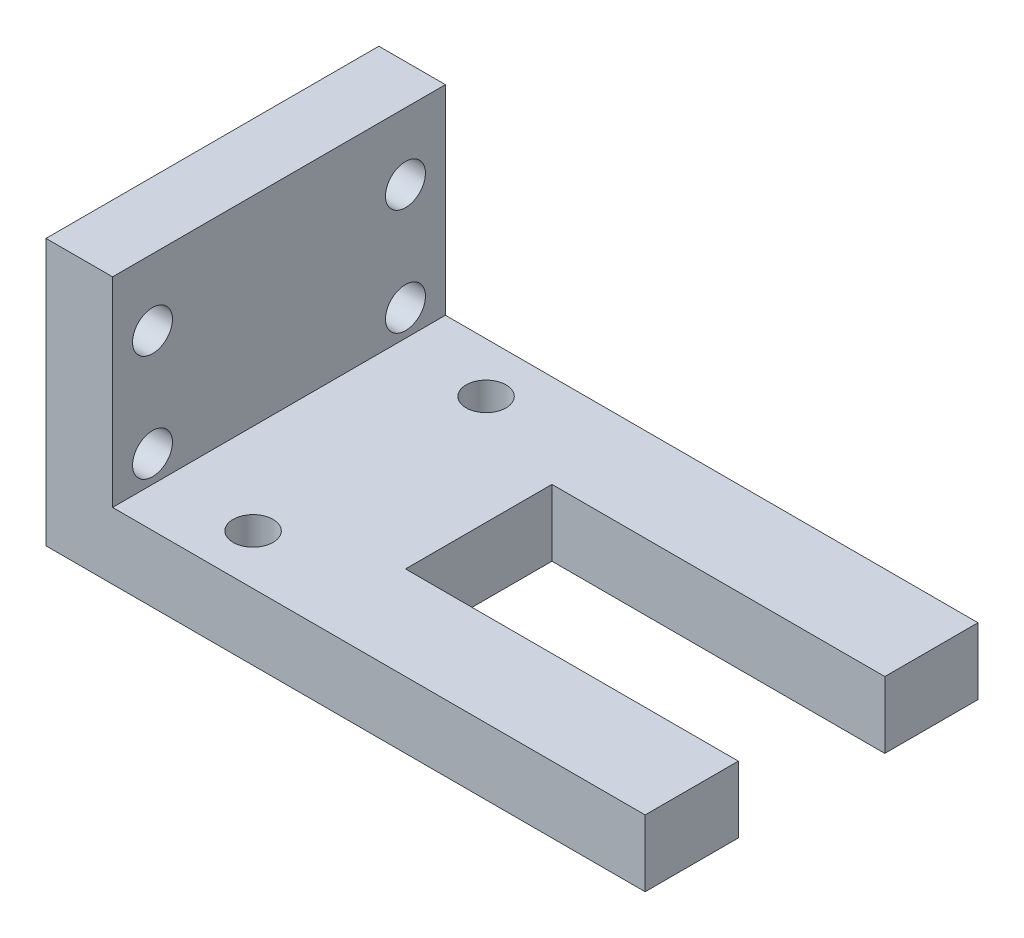
from build123d import *

# Parameters (mm, degrees)
BOSS_EXTRUDE1_DEPTH = 25
SKETCH2_R           = 1.5
CUT_EXTRUDE1_DEPTH  = 26
SKETCH3_R           = 1.5
SKETCH3_W           = 25
SKETCH3_H           = 9
CUT_EXTRUDE2_DEPTH  = 10
SKETCH5_W           = 25
SKETCH5_H           = 1
CUT_EXTRUDE3_DEPTH  = 50


with BuildPart() as part:
    # Sketch1 → Boss-Extrude1 (new body)
    with BuildSketch(Plane.XY):
        Polygon((0, 27.931034483), (0, 12.931034483), (40, 12.931034483), (40, 7.931034483), (-5, 7.931034483), (-5, 27.931034483), align=None)
    extrude(amount=-BOSS_EXTRUDE1_DEPTH)

    # Sketch2 → Cut-Extrude1 (cut)
    with BuildSketch(Plane.ZY.offset(5)):
        with Locations((-22, 22.931034483)):
            Circle(SKETCH2_R)
        with Locations((-3, 22.931034483)):
            Circle(SKETCH2_R)
        with Locations((-3, 14.931034483)):
            Circle(SKETCH2_R)
        with Locations((-22, 14.931034483)):
            Circle(SKETCH2_R)
    extrude(amount=-CUT_EXTRUDE1_DEPTH, mode=Mode.SUBTRACT)

    # Sketch3 → Cut-Extrude2 (cut)
    with BuildSketch(Plane.XZ.offset(-7.931034483)):
        with Locations((6.802030066, -3.75)):
            Circle(SKETCH3_R)
        with Locations((6.802030066, -21.25)):
            Circle(SKETCH3_R)
        with Locations((27.5, -12.5)):
            Rectangle(SKETCH3_W, SKETCH3_H)
    extrude(amount=-CUT_EXTRUDE2_DEPTH, mode=Mode.SUBTRACT)

    # Sketch5 → Cut-Extrude3 (cut)
    with BuildSketch(Plane.XZ.offset(-7.931034483)):
        with Locations((27.5, -7.5)):
            Rectangle(SKETCH5_W, SKETCH5_H)
        with Locations((27.5, -17.5)):
            Rectangle(SKETCH5_W, SKETCH5_H)
    extrude(amount=-CUT_EXTRUDE3_DEPTH, mode=Mode.SUBTRACT)


solid = part.part
